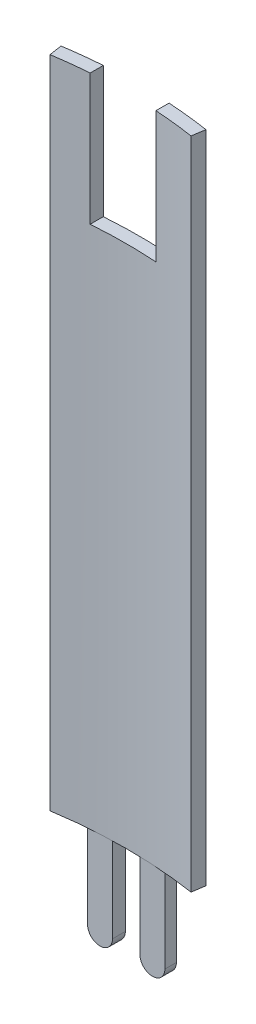
from build123d import *

# Parameters (mm, degrees)
BOSS_EXTRUDE1_DEPTH      = 127
BOSS_EXTRUDE5_REACH      = 249.033
BOSS_EXTRUDE5_END_RADIUS = 92.075
BOSS_EXTRUDE5_START      = -89.535
CUT_EXTRUDE4_REACH       = 159.498
CUT_EXTRUDE4_END_RADIUS  = 92.075
SKETCH9_W                = 12.7
SKETCH9_H                = 25.4


with BuildPart() as part:
    # Sketch1 → Boss-Extrude1 (new body)
    with BuildSketch(Plane(origin=(0, 0, 0), x_dir=(1, 0, 0), z_dir=(0, 1, 0))):
        with BuildLine():
            Line((-14.105106383, 90.988194833), (-13.716, 88.478175665))
            ThreePointArc((-13.716, 88.478175665), (-0.054221583, 89.534983582), (13.608826801, 88.494723335))
            Line((13.608826801, 88.494723335), (13.994892809, 91.00521194))
            ThreePointArc((13.994892809, 91.00521194), (-0.055759783, 92.074983116), (-14.105106383, 90.988194833))
        make_face()
    extrude(amount=BOSS_EXTRUDE1_DEPTH)

    # Boss-Extrude5: up to this cylinder (the profile starts inside it)
    boss_extrude5_end = Plane(origin=(0, -9.210463, 0), z_dir=(0, -1, 0)) * Cylinder(BOSS_EXTRUDE5_END_RADIUS, 683.216, mode=Mode.PRIVATE)
    # Sketch7 → Boss-Extrude5 (add, up to the surface)
    with BuildSketch(Plane.XY.offset(BOSS_EXTRUDE5_START), mode=Mode.PRIVATE) as boss_extrude5_sk1:
        with BuildLine():
            Line((-2.667, -16.51), (-2.667, 0))
            Line((-2.667, 0), (-7.493, 0))
            Line((-7.493, 0), (-7.493, -16.51))
            ThreePointArc((-7.493, -16.51), (-5.08, -18.923), (-2.667, -16.51))
        make_face()
    boss_extrude5_tool1 = extrude(boss_extrude5_sk1.sketch, amount=-BOSS_EXTRUDE5_REACH, mode=Mode.PRIVATE) & boss_extrude5_end
    add(boss_extrude5_tool1.solids().sort_by_distance((-5.08, -9.210463, -89.535))[0])
    # Sketch7 → Boss-Extrude5 (add, up to the surface)
    with BuildSketch(Plane.XY.offset(BOSS_EXTRUDE5_START), mode=Mode.PRIVATE) as boss_extrude5_sk2:
        with BuildLine():
            Line((2.667, 0), (2.667, -16.51))
            ThreePointArc((2.667, -16.51), (5.08, -18.923), (7.493, -16.51))
            Line((7.493, -16.51), (7.493, 0))
            Line((7.493, 0), (2.667, 0))
        make_face()
    boss_extrude5_tool2 = extrude(boss_extrude5_sk2.sketch, amount=-BOSS_EXTRUDE5_REACH, mode=Mode.PRIVATE) & boss_extrude5_end
    add(boss_extrude5_tool2.solids().sort_by_distance((5.08, -9.210463, -89.535))[0])

    # Cut-Extrude4: up to this cylinder (the profile starts inside it)
    cut_extrude4_end = Plane(origin=(0, 114.3, 0), z_dir=(0, -1, 0)) * Cylinder(CUT_EXTRUDE4_END_RADIUS, 504.146, mode=Mode.PRIVATE)
    # Sketch9 → Cut-Extrude4 (cut, up to the surface)
    with BuildSketch(Plane.XY, mode=Mode.PRIVATE) as cut_extrude4_sk1:
        with Locations((-0.389106383, 114.3)):
            Rectangle(SKETCH9_W, SKETCH9_H)
    cut_extrude4_tool1 = extrude(cut_extrude4_sk1.sketch, amount=-CUT_EXTRUDE4_REACH, mode=Mode.PRIVATE) & cut_extrude4_end
    add(cut_extrude4_tool1.solids().sort_by_distance((-0.389106, 114.3, 0))[0], mode=Mode.SUBTRACT)


solid = part.part
